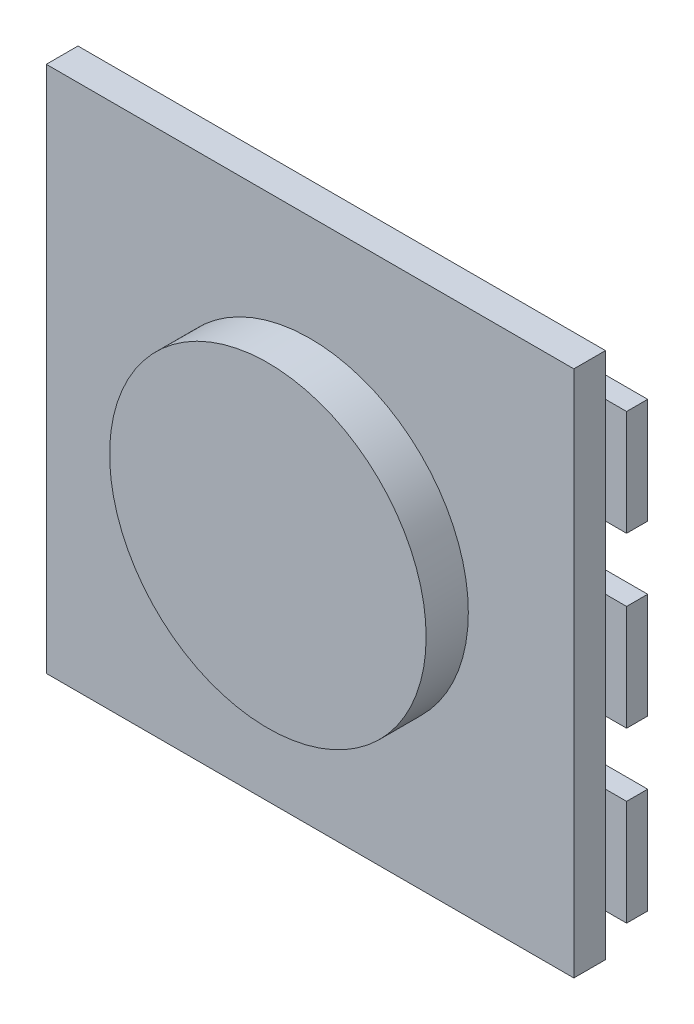
from build123d import *

# Parameters (mm, degrees)
ESQUISSE1_W        = 5
ESQUISSE1_H        = 5
BOSS_EXTRU_2_DEPTH = 0.3
ESQUISSE1_5_R      = 1.5
BOSS_EXTRU_3_DEPTH = 0.7
ESQUISSE1_6_R      = 0.394936167
BOSS_EXTRU_4_DEPTH = 0.1
ESQUISSE1_7_W      = 1
ESQUISSE1_7_H      = 1
ESQUISSE1_7_W_2    = 0.789872334
BOSS_EXTRU_5_DEPTH = 0.2


with BuildPart() as part:
    # Esquisse1 → Boss.-Extru.2 (new body)
    with BuildSketch(Plane.XY):
        with Locations((-11.706621497, -12.638942011)):
            Rectangle(ESQUISSE1_W, ESQUISSE1_H)
    extrude(amount=BOSS_EXTRU_2_DEPTH)

    # Esquisse1_5 → Boss.-Extru.3 (add)
    with BuildSketch(Plane.XY):
        with Locations((-11.706621497, -12.638942011)):
            Circle(ESQUISSE1_5_R)
    extrude(amount=BOSS_EXTRU_3_DEPTH)

    # Esquisse1_6 → Boss.-Extru.4 (add)
    with BuildSketch(Plane.XY):
        with Locations((-11.706621497, -12.638942011)):
            Circle(ESQUISSE1_6_R)
    extrude(amount=-BOSS_EXTRU_4_DEPTH)

    # Esquisse1_7 → Boss.-Extru.5 (add)
    with BuildSketch(Plane.XY):
        with Locations((-13.906621497, -12.638942011)):
            Rectangle(ESQUISSE1_7_W, ESQUISSE1_7_H)
        with Locations((-13.906621497, -11.038942011)):
            Rectangle(ESQUISSE1_7_W, ESQUISSE1_7_H)
        with Locations((-13.906621497, -14.238942011)):
            Rectangle(ESQUISSE1_7_W, ESQUISSE1_7_H)
        with Locations((-9.506621497, -11.038942011)):
            Rectangle(ESQUISSE1_7_W, ESQUISSE1_7_H)
        with Locations((-9.506621497, -14.238942011)):
            Rectangle(ESQUISSE1_7_W, ESQUISSE1_7_H)
        with Locations((-9.506621497, -12.638942011)):
            Rectangle(ESQUISSE1_7_W, ESQUISSE1_7_H)
        with Locations((-11.612951228, -11.138942011)):
            Rectangle(ESQUISSE1_7_W_2, ESQUISSE1_7_H)
        with Locations((-11.706621497, -14.138942011)):
            Rectangle(ESQUISSE1_7_W_2, ESQUISSE1_7_H)
    extrude(amount=-BOSS_EXTRU_5_DEPTH)


solid = part.part
